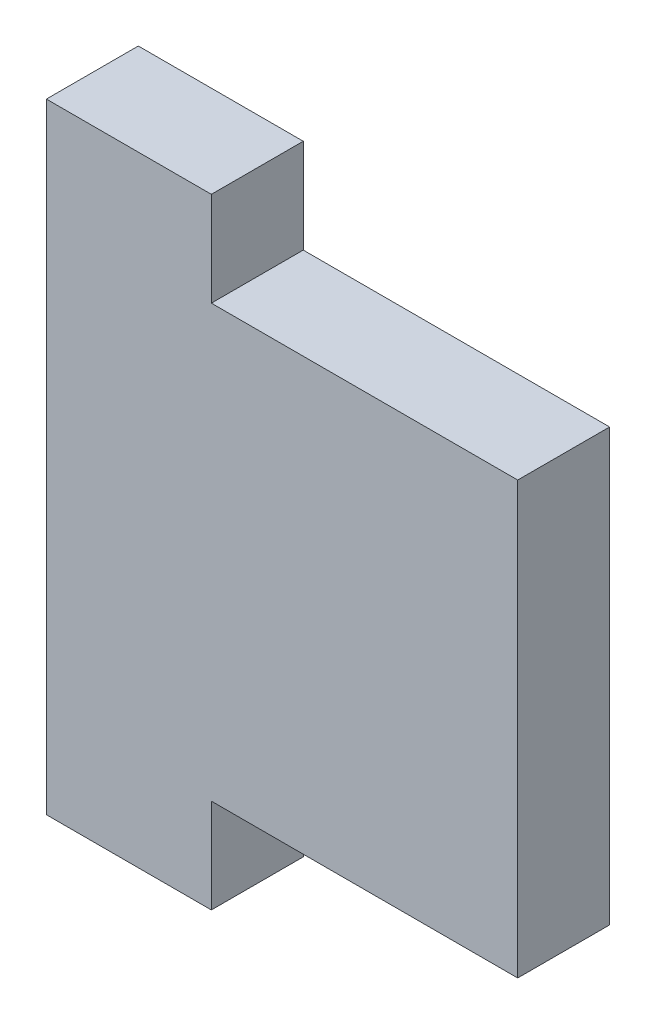
from build123d import *

# Parameters (mm, degrees)
BOSS_EXTRUDE1_DEPTH = 2.4765


with BuildPart() as part:
    # Sketch1 → Boss-Extrude1 (new, symmetric)
    with BuildSketch(Plane.XY):
        Polygon((-54.483, 11.6205), (-70.993, 11.6205), (-70.993, 16.7005), (-79.883, 16.7005), (-79.883, -16.7005), (-70.993, -16.7005), (-70.993, -11.6205), (-54.483, -11.6205), align=None)
    extrude(amount=BOSS_EXTRUDE1_DEPTH, both=True)


solid = part.part
